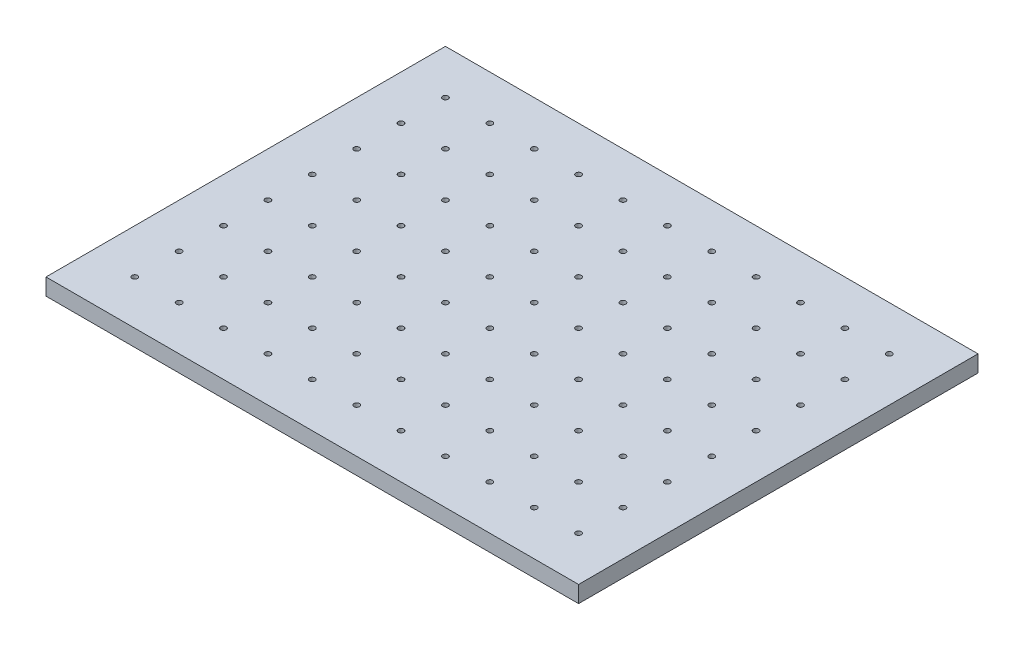
from build123d import *

# Parameters (mm, degrees)
SKETCH1_W           = 609.6
SKETCH1_H           = 457.2
SKETCH1_R           = 3.175
BOSS_EXTRUDE1_DEPTH = 19.05


with BuildPart() as part:
    # Sketch1 → Boss-Extrude1 (new body)
    with BuildSketch(Plane(origin=(0, 0, 0), x_dir=(1, 0, 0), z_dir=(0, 1, 0))):
        with Locations((304.8, -228.6)):
            Rectangle(SKETCH1_W, SKETCH1_H)
        with Locations((50.8, -50.8)):
            Circle(SKETCH1_R, mode=Mode.SUBTRACT)
        with Locations((101.6, -50.8)):
            Circle(SKETCH1_R, mode=Mode.SUBTRACT)
        with Locations((152.4, -50.8)):
            Circle(SKETCH1_R, mode=Mode.SUBTRACT)
        with Locations((203.2, -50.8)):
            Circle(SKETCH1_R, mode=Mode.SUBTRACT)
        with Locations((254, -50.8)):
            Circle(SKETCH1_R, mode=Mode.SUBTRACT)
        with Locations((304.8, -50.8)):
            Circle(SKETCH1_R, mode=Mode.SUBTRACT)
        with Locations((355.6, -50.8)):
            Circle(SKETCH1_R, mode=Mode.SUBTRACT)
        with Locations((406.4, -50.8)):
            Circle(SKETCH1_R, mode=Mode.SUBTRACT)
        with Locations((457.2, -50.8)):
            Circle(SKETCH1_R, mode=Mode.SUBTRACT)
        with Locations((508, -50.8)):
            Circle(SKETCH1_R, mode=Mode.SUBTRACT)
        with Locations((558.8, -50.8)):
            Circle(SKETCH1_R, mode=Mode.SUBTRACT)
        with Locations((50.8, -101.6)):
            Circle(SKETCH1_R, mode=Mode.SUBTRACT)
        with Locations((101.6, -101.6)):
            Circle(SKETCH1_R, mode=Mode.SUBTRACT)
        with Locations((152.4, -101.6)):
            Circle(SKETCH1_R, mode=Mode.SUBTRACT)
        with Locations((203.2, -101.6)):
            Circle(SKETCH1_R, mode=Mode.SUBTRACT)
        with Locations((254, -101.6)):
            Circle(SKETCH1_R, mode=Mode.SUBTRACT)
        with Locations((304.8, -101.6)):
            Circle(SKETCH1_R, mode=Mode.SUBTRACT)
        with Locations((355.6, -101.6)):
            Circle(SKETCH1_R, mode=Mode.SUBTRACT)
        with Locations((406.4, -101.6)):
            Circle(SKETCH1_R, mode=Mode.SUBTRACT)
        with Locations((457.2, -101.6)):
            Circle(SKETCH1_R, mode=Mode.SUBTRACT)
        with Locations((508, -101.6)):
            Circle(SKETCH1_R, mode=Mode.SUBTRACT)
        with Locations((558.8, -101.6)):
            Circle(SKETCH1_R, mode=Mode.SUBTRACT)
        with Locations((50.8, -152.4)):
            Circle(SKETCH1_R, mode=Mode.SUBTRACT)
        with Locations((101.6, -152.4)):
            Circle(SKETCH1_R, mode=Mode.SUBTRACT)
        with Locations((152.4, -152.4)):
            Circle(SKETCH1_R, mode=Mode.SUBTRACT)
        with Locations((203.2, -152.4)):
            Circle(SKETCH1_R, mode=Mode.SUBTRACT)
        with Locations((254, -152.4)):
            Circle(SKETCH1_R, mode=Mode.SUBTRACT)
        with Locations((304.8, -152.4)):
            Circle(SKETCH1_R, mode=Mode.SUBTRACT)
        with Locations((355.6, -152.4)):
            Circle(SKETCH1_R, mode=Mode.SUBTRACT)
        with Locations((406.4, -152.4)):
            Circle(SKETCH1_R, mode=Mode.SUBTRACT)
        with Locations((457.2, -152.4)):
            Circle(SKETCH1_R, mode=Mode.SUBTRACT)
        with Locations((508, -152.4)):
            Circle(SKETCH1_R, mode=Mode.SUBTRACT)
        with Locations((558.8, -152.4)):
            Circle(SKETCH1_R, mode=Mode.SUBTRACT)
        with Locations((50.8, -203.2)):
            Circle(SKETCH1_R, mode=Mode.SUBTRACT)
        with Locations((101.6, -203.2)):
            Circle(SKETCH1_R, mode=Mode.SUBTRACT)
        with Locations((152.4, -203.2)):
            Circle(SKETCH1_R, mode=Mode.SUBTRACT)
        with Locations((203.2, -203.2)):
            Circle(SKETCH1_R, mode=Mode.SUBTRACT)
        with Locations((254, -203.2)):
            Circle(SKETCH1_R, mode=Mode.SUBTRACT)
        with Locations((304.8, -203.2)):
            Circle(SKETCH1_R, mode=Mode.SUBTRACT)
        with Locations((355.6, -203.2)):
            Circle(SKETCH1_R, mode=Mode.SUBTRACT)
        with Locations((406.4, -203.2)):
            Circle(SKETCH1_R, mode=Mode.SUBTRACT)
        with Locations((457.2, -203.2)):
            Circle(SKETCH1_R, mode=Mode.SUBTRACT)
        with Locations((508, -203.2)):
            Circle(SKETCH1_R, mode=Mode.SUBTRACT)
        with Locations((558.8, -203.2)):
            Circle(SKETCH1_R, mode=Mode.SUBTRACT)
        with Locations((50.8, -254)):
            Circle(SKETCH1_R, mode=Mode.SUBTRACT)
        with Locations((101.6, -254)):
            Circle(SKETCH1_R, mode=Mode.SUBTRACT)
        with Locations((152.4, -254)):
            Circle(SKETCH1_R, mode=Mode.SUBTRACT)
        with Locations((203.2, -254)):
            Circle(SKETCH1_R, mode=Mode.SUBTRACT)
        with Locations((254, -254)):
            Circle(SKETCH1_R, mode=Mode.SUBTRACT)
        with Locations((304.8, -254)):
            Circle(SKETCH1_R, mode=Mode.SUBTRACT)
        with Locations((355.6, -254)):
            Circle(SKETCH1_R, mode=Mode.SUBTRACT)
        with Locations((406.4, -254)):
            Circle(SKETCH1_R, mode=Mode.SUBTRACT)
        with Locations((457.2, -254)):
            Circle(SKETCH1_R, mode=Mode.SUBTRACT)
        with Locations((508, -254)):
            Circle(SKETCH1_R, mode=Mode.SUBTRACT)
        with Locations((558.8, -254)):
            Circle(SKETCH1_R, mode=Mode.SUBTRACT)
        with Locations((50.8, -304.8)):
            Circle(SKETCH1_R, mode=Mode.SUBTRACT)
        with Locations((101.6, -304.8)):
            Circle(SKETCH1_R, mode=Mode.SUBTRACT)
        with Locations((152.4, -304.8)):
            Circle(SKETCH1_R, mode=Mode.SUBTRACT)
        with Locations((203.2, -304.8)):
            Circle(SKETCH1_R, mode=Mode.SUBTRACT)
        with Locations((254, -304.8)):
            Circle(SKETCH1_R, mode=Mode.SUBTRACT)
        with Locations((304.8, -304.8)):
            Circle(SKETCH1_R, mode=Mode.SUBTRACT)
        with Locations((355.6, -304.8)):
            Circle(SKETCH1_R, mode=Mode.SUBTRACT)
        with Locations((406.4, -304.8)):
            Circle(SKETCH1_R, mode=Mode.SUBTRACT)
        with Locations((457.2, -304.8)):
            Circle(SKETCH1_R, mode=Mode.SUBTRACT)
        with Locations((508, -304.8)):
            Circle(SKETCH1_R, mode=Mode.SUBTRACT)
        with Locations((558.8, -304.8)):
            Circle(SKETCH1_R, mode=Mode.SUBTRACT)
        with Locations((50.8, -355.6)):
            Circle(SKETCH1_R, mode=Mode.SUBTRACT)
        with Locations((101.6, -355.6)):
            Circle(SKETCH1_R, mode=Mode.SUBTRACT)
        with Locations((152.4, -355.6)):
            Circle(SKETCH1_R, mode=Mode.SUBTRACT)
        with Locations((203.2, -355.6)):
            Circle(SKETCH1_R, mode=Mode.SUBTRACT)
        with Locations((254, -355.6)):
            Circle(SKETCH1_R, mode=Mode.SUBTRACT)
        with Locations((304.8, -355.6)):
            Circle(SKETCH1_R, mode=Mode.SUBTRACT)
        with Locations((355.6, -355.6)):
            Circle(SKETCH1_R, mode=Mode.SUBTRACT)
        with Locations((406.4, -355.6)):
            Circle(SKETCH1_R, mode=Mode.SUBTRACT)
        with Locations((457.2, -355.6)):
            Circle(SKETCH1_R, mode=Mode.SUBTRACT)
        with Locations((508, -355.6)):
            Circle(SKETCH1_R, mode=Mode.SUBTRACT)
        with Locations((558.8, -355.6)):
            Circle(SKETCH1_R, mode=Mode.SUBTRACT)
        with Locations((50.8, -406.4)):
            Circle(SKETCH1_R, mode=Mode.SUBTRACT)
        with Locations((101.6, -406.4)):
            Circle(SKETCH1_R, mode=Mode.SUBTRACT)
        with Locations((152.4, -406.4)):
            Circle(SKETCH1_R, mode=Mode.SUBTRACT)
        with Locations((203.2, -406.4)):
            Circle(SKETCH1_R, mode=Mode.SUBTRACT)
        with Locations((254, -406.4)):
            Circle(SKETCH1_R, mode=Mode.SUBTRACT)
        with Locations((304.8, -406.4)):
            Circle(SKETCH1_R, mode=Mode.SUBTRACT)
        with Locations((355.6, -406.4)):
            Circle(SKETCH1_R, mode=Mode.SUBTRACT)
        with Locations((406.4, -406.4)):
            Circle(SKETCH1_R, mode=Mode.SUBTRACT)
        with Locations((457.2, -406.4)):
            Circle(SKETCH1_R, mode=Mode.SUBTRACT)
        with Locations((508, -406.4)):
            Circle(SKETCH1_R, mode=Mode.SUBTRACT)
        with Locations((558.8, -406.4)):
            Circle(SKETCH1_R, mode=Mode.SUBTRACT)
    extrude(amount=BOSS_EXTRUDE1_DEPTH)


solid = part.part
